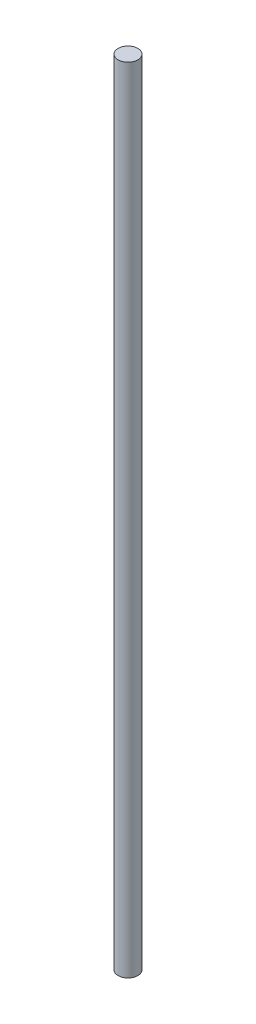
from build123d import *

# Parameters (mm, degrees)
SKETCH_1_R      = 5
EXTRUDE_1_DEPTH = 400


with BuildPart() as part:
    # 草图1 → 凸台-拉伸1 (new body)
    with BuildSketch(Plane(origin=(0, 0, 0), x_dir=(1, 0, 0), z_dir=(0, 1, 0))):
        Circle(SKETCH_1_R)
    extrude(amount=EXTRUDE_1_DEPTH)


solid = part.part
